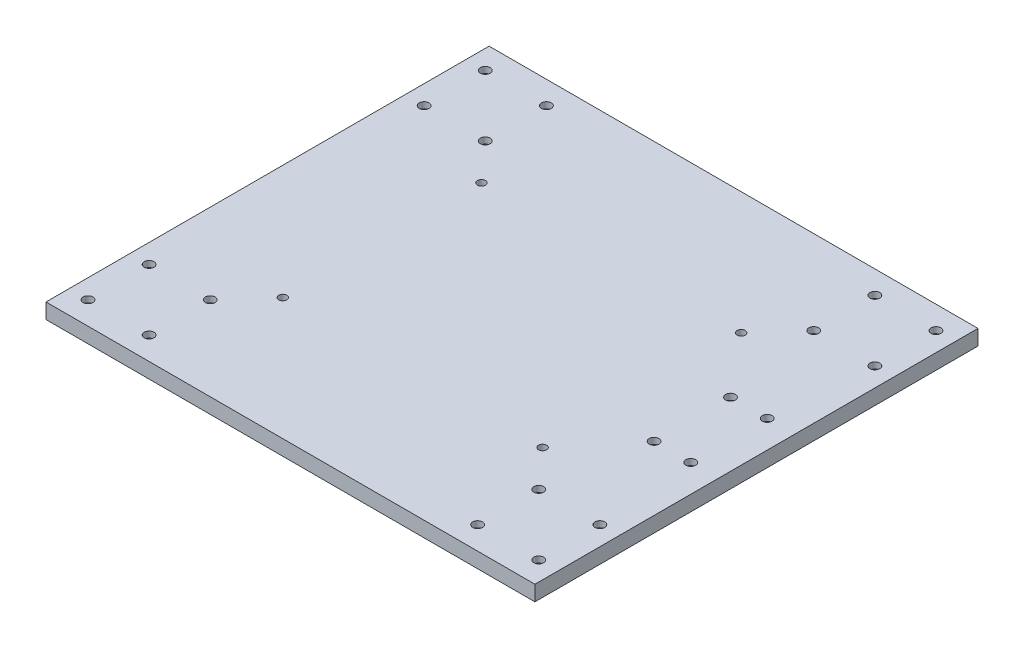
from build123d import *

# Parameters (mm, degrees)
SKETCH_1_W          = 320
SKETCH_1_H          = 290
SKETCH_1_R          = 2.65
SKETCH_1_R_2        = 3.2
EXTRUDE_3_DEPTH     = 10
SKETCH_5_R          = 5.25
CUT_EXTRUDE_1_DEPTH = 6


with BuildPart() as part:
    # Эскиз1 → Бобышка-Вытянуть3 (new body)
    with BuildSketch(Plane(origin=(0, 0, 0), x_dir=(1, 0, 0), z_dir=(0, 1, 0))):
        Rectangle(SKETCH_1_W, SKETCH_1_H)
        with Locations((-85, 65)):
            Circle(SKETCH_1_R, mode=Mode.SUBTRACT)
        with Locations((85, 65)):
            Circle(SKETCH_1_R, mode=Mode.SUBTRACT)
        with Locations((85, -65)):
            Circle(SKETCH_1_R, mode=Mode.SUBTRACT)
        with Locations((-85, -65)):
            Circle(SKETCH_1_R, mode=Mode.SUBTRACT)
        with Locations((-147.5, 130)):
            Circle(SKETCH_1_R_2, mode=Mode.SUBTRACT)
        with Locations((-107.5, 130)):
            Circle(SKETCH_1_R_2, mode=Mode.SUBTRACT)
        with Locations((-107.5, 90)):
            Circle(SKETCH_1_R_2, mode=Mode.SUBTRACT)
        with Locations((-147.5, 90)):
            Circle(SKETCH_1_R_2, mode=Mode.SUBTRACT)
        with Locations((-147.5, -90)):
            Circle(SKETCH_1_R_2, mode=Mode.SUBTRACT)
        with Locations((-107.5, -90)):
            Circle(SKETCH_1_R_2, mode=Mode.SUBTRACT)
        with Locations((-107.5, -130)):
            Circle(SKETCH_1_R_2, mode=Mode.SUBTRACT)
        with Locations((-147.5, -130)):
            Circle(SKETCH_1_R_2, mode=Mode.SUBTRACT)
        with Locations((147.5, -130)):
            Circle(SKETCH_1_R_2, mode=Mode.SUBTRACT)
        with Locations((107.5, -130)):
            Circle(SKETCH_1_R_2, mode=Mode.SUBTRACT)
        with Locations((107.5, -90)):
            Circle(SKETCH_1_R_2, mode=Mode.SUBTRACT)
        with Locations((147.5, -90)):
            Circle(SKETCH_1_R_2, mode=Mode.SUBTRACT)
        with Locations((147.5, 90)):
            Circle(SKETCH_1_R_2, mode=Mode.SUBTRACT)
        with Locations((107.5, 90)):
            Circle(SKETCH_1_R_2, mode=Mode.SUBTRACT)
        with Locations((107.5, 130)):
            Circle(SKETCH_1_R_2, mode=Mode.SUBTRACT)
        with Locations((147.5, 130)):
            Circle(SKETCH_1_R_2, mode=Mode.SUBTRACT)
        with Locations((142, 25)):
            Circle(SKETCH_1_R_2, mode=Mode.SUBTRACT)
        with Locations((118, 25)):
            Circle(SKETCH_1_R_2, mode=Mode.SUBTRACT)
        with Locations((118, -25)):
            Circle(SKETCH_1_R_2, mode=Mode.SUBTRACT)
        with Locations((142, -25)):
            Circle(SKETCH_1_R_2, mode=Mode.SUBTRACT)
    extrude(amount=EXTRUDE_3_DEPTH)

    # Эскиз5 → Вырез-Вытянуть1 (cut)
    with BuildSketch(Plane.XZ):
        with Locations((-147.5, 130)):
            Circle(SKETCH_5_R)
        with Locations((-107.5, 130)):
            Circle(SKETCH_5_R)
        with Locations((-107.5, 90)):
            Circle(SKETCH_5_R)
        with Locations((-147.5, 90)):
            Circle(SKETCH_5_R)
        with Locations((-147.5, -90)):
            Circle(SKETCH_5_R)
        with Locations((-107.5, -90)):
            Circle(SKETCH_5_R)
        with Locations((-107.5, -130)):
            Circle(SKETCH_5_R)
        with Locations((-147.5, -130)):
            Circle(SKETCH_5_R)
        with Locations((147.5, -130)):
            Circle(SKETCH_5_R)
        with Locations((107.5, -130)):
            Circle(SKETCH_5_R)
        with Locations((107.5, -90)):
            Circle(SKETCH_5_R)
        with Locations((147.5, -90)):
            Circle(SKETCH_5_R)
        with Locations((147.5, 90)):
            Circle(SKETCH_5_R)
        with Locations((107.5, 90)):
            Circle(SKETCH_5_R)
        with Locations((107.5, 130)):
            Circle(SKETCH_5_R)
        with Locations((147.5, 130)):
            Circle(SKETCH_5_R)
        with Locations((142, 25)):
            Circle(SKETCH_5_R)
        with Locations((118, 25)):
            Circle(SKETCH_5_R)
        with Locations((118, -25)):
            Circle(SKETCH_5_R)
        with Locations((142, -25)):
            Circle(SKETCH_5_R)
    extrude(amount=-CUT_EXTRUDE_1_DEPTH, mode=Mode.SUBTRACT)


solid = part.part
